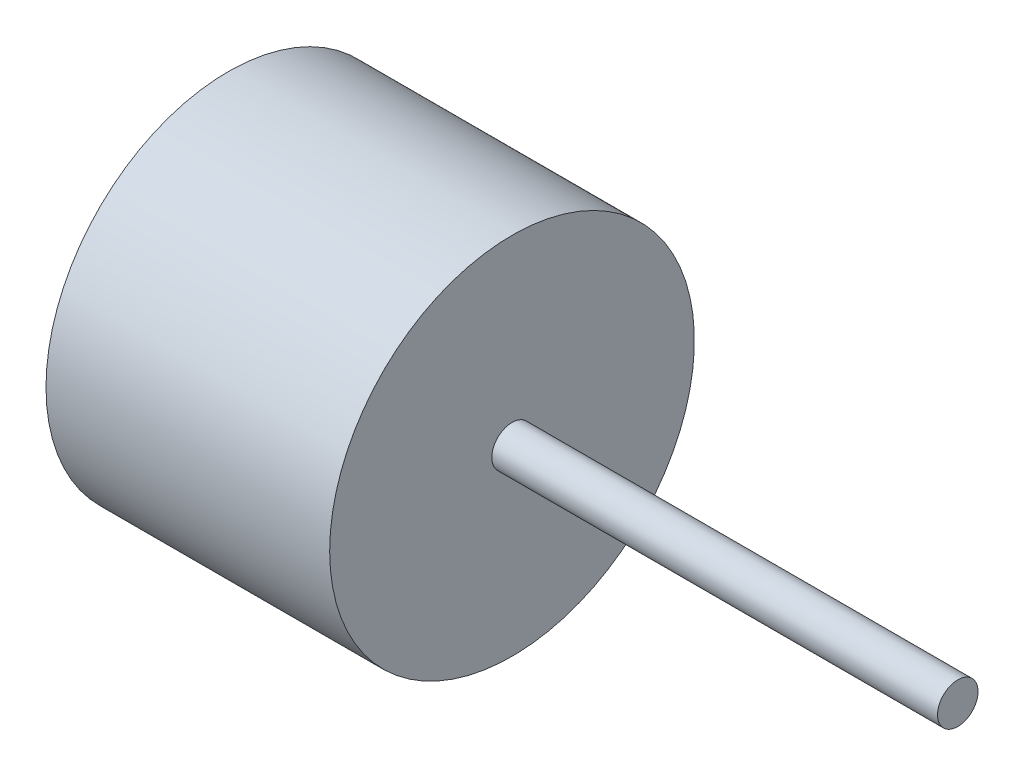
from build123d import *


with BuildPart() as part:
    # Esquisse1 → Révolution1 (revolve)
    with BuildSketch(Plane.XY):
        Polygon((22, 0), (22, 1), (0, 1), (0, 9), (-14, 9), (-14, 0), align=None)
    revolve(axis=Axis((-38.215059524, 0, 0), (1, 0, 0)))


solid = part.part
